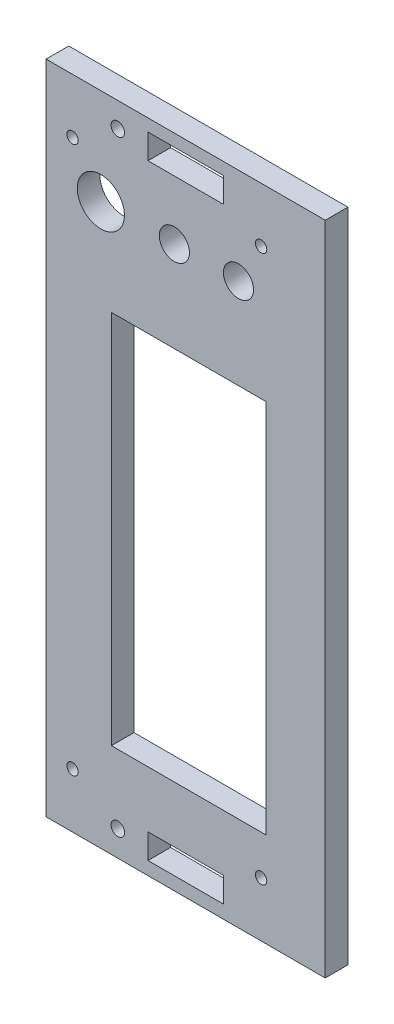
from build123d import *

# Parameters (mm, degrees)
MODEL_W                  = 73.99999408
MODEL_H                  = 173.99998608
MODEL_R                  = 1.5
MODEL_R_2                = 1.799999856
MODEL_R_3                = 1.49999988
MODEL_R_4                = 3.99999968
MODEL_R_5                = 6.2499995
MODEL_W_2                = 40.99999672
MODEL_H_2                = 99.49999204
MODEL_W_3                = 19.999994237
MODEL_H_3                = 6.600001389
RESSALTO_EXTRUS_O1_DEPTH = 6


with BuildPart() as part:
    # Model → Ressalto-extrusão1 (new body)
    with BuildSketch(Plane.XY):
        with Locations((67.822014365, 94.353551358)):
            Rectangle(MODEL_W, MODEL_H)
        with Locations((87.822012765, 21.853557158)):
            Circle(MODEL_R, mode=Mode.SUBTRACT)
        with Locations((49.822015805, 14.131755092)):
            Circle(MODEL_R_2, mode=Mode.SUBTRACT)
        with Locations((37.822016765, 21.853557158)):
            Circle(MODEL_R_3, mode=Mode.SUBTRACT)
        with Locations((87.822012765, 166.853545558)):
            Circle(MODEL_R_3, mode=Mode.SUBTRACT)
        with Locations((81.822013245, 155.853546358)):
            Circle(MODEL_R_4, mode=Mode.SUBTRACT)
        with Locations((64.822014605, 155.853546358)):
            Circle(MODEL_R_4, mode=Mode.SUBTRACT)
        with Locations((45.322016165, 155.853546358)):
            Circle(MODEL_R_5, mode=Mode.SUBTRACT)
        with Locations((37.822016765, 166.853545558)):
            Circle(MODEL_R_3, mode=Mode.SUBTRACT)
        with Locations((49.822015805, 174.808809717)):
            Circle(MODEL_R_2, mode=Mode.SUBTRACT)
        with Locations((68.622014301, 82.103552338)):
            Rectangle(MODEL_W_2, MODEL_H_2, mode=Mode.SUBTRACT)
        with Locations((67.822014365, 14.131755092)):
            Rectangle(MODEL_W_3, MODEL_H_3, mode=Mode.SUBTRACT)
        with Locations((67.822014365, 174.808809717)):
            Rectangle(MODEL_W_3, MODEL_H_3, mode=Mode.SUBTRACT)
    extrude(amount=RESSALTO_EXTRUS_O1_DEPTH)


solid = part.part
